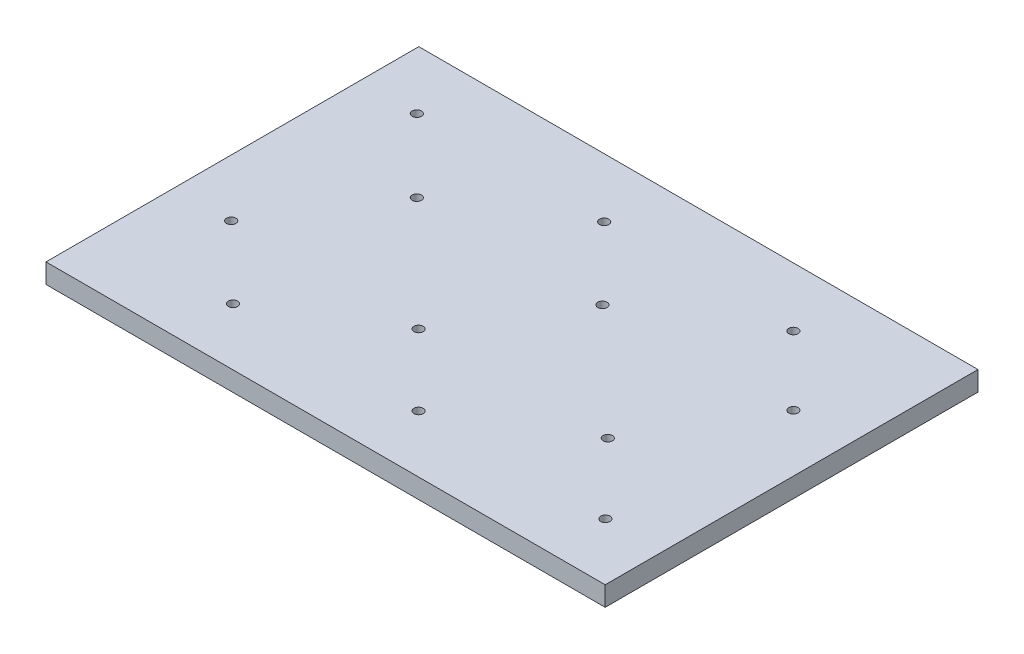
from build123d import *

# Parameters (mm, degrees)
SKETCH1_W                       = 70
SKETCH1_H                       = 50
BOSS_EXTRUDE1_DEPTH             = 6.35
SKETCH2_W                       = 60
SKETCH2_H                       = 40
CUT_EXTRUDE1_DEPTH              = 3.175
SKETCH3_W                       = 10
SKETCH3_H                       = 10
BOSS_EXTRUDE2_DEPTH             = 0.55
LPATTERN1_COUNT                 = 3
LPATTERN1_PITCH                 = 20
LPATTERN1_COUNT_DIR2            = 2
LPATTERN1_PITCH_DIR2            = 20
DIVIDERS_DEPTH                  = 2
FILLET4_R                       = 3.175
FILLET6_R                       = 3.175
FILLET7_R                       = 6.35
SKETCH11_W                      = 61.55259076
SKETCH11_H                      = 41.010160592
BOSS_EXTRUDE3_DEPTH             = 2.1
SKETCH13_W                      = 0.5
SKETCH13_H                      = 2.1
F_1_0MM_DOWEL_HOLE1_AT_2_COUNT  = 2
F_1_0MM_DOWEL_HOLE1_AT_2_PITCH  = 11.047071486
F_1_0MM_DOWEL_HOLE1_AT_3_COUNT  = 2
F_1_0MM_DOWEL_HOLE1_AT_3_PITCH  = 19.912818023
F_1_0MM_DOWEL_HOLE1_AT_4_COUNT  = 2
F_1_0MM_DOWEL_HOLE1_AT_4_PITCH  = 28.618883578
F_1_0MM_DOWEL_HOLE1_AT_5_COUNT  = 2
F_1_0MM_DOWEL_HOLE1_AT_5_PITCH  = 28.29712794
F_1_0MM_DOWEL_HOLE1_AT_6_COUNT  = 2
F_1_0MM_DOWEL_HOLE1_AT_6_PITCH  = 39.07246023
F_1_0MM_DOWEL_HOLE1_AT_7_COUNT  = 2
F_1_0MM_DOWEL_HOLE1_AT_7_PITCH  = 28.803722668
F_1_0MM_DOWEL_HOLE1_AT_8_COUNT  = 2
F_1_0MM_DOWEL_HOLE1_AT_8_PITCH  = 20.104903085
F_1_0MM_DOWEL_HOLE1_AT_9_COUNT  = 2
F_1_0MM_DOWEL_HOLE1_AT_9_PITCH  = 40.40189123
F_1_0MM_DOWEL_HOLE1_AT_10_COUNT = 2
F_1_0MM_DOWEL_HOLE1_AT_10_PITCH = 48.329363179
F_1_0MM_DOWEL_HOLE1_AT_11_COUNT = 2
F_1_0MM_DOWEL_HOLE1_AT_11_PITCH = 45.042570271
F_1_0MM_DOWEL_HOLE1_AT_12_COUNT = 2
F_1_0MM_DOWEL_HOLE1_AT_12_PITCH = 55.131944827


with BuildPart() as part:
    # Sketch1 → Boss-Extrude1 (new body)
    with BuildSketch(Plane(origin=(0, 0, 0), x_dir=(1, 0, 0), z_dir=(0, 1, 0))):
        Rectangle(SKETCH1_W, SKETCH1_H)
    extrude(amount=BOSS_EXTRUDE1_DEPTH)

    # Sketch2 → Cut-Extrude1 (cut)
    with BuildSketch(Plane(origin=(0, 6.35, 0), x_dir=(1, 0, 0), z_dir=(0, 1, 0))):
        Rectangle(SKETCH2_W, SKETCH2_H)
    extrude(amount=-CUT_EXTRUDE1_DEPTH, mode=Mode.SUBTRACT)

    # Sketch3 → Boss-Extrude2 (add)
    with BuildSketch(Plane(origin=(0, 3.175, 0), x_dir=(1, 0, 0), z_dir=(0, 1, 0))):
        with Locations((-20, 10)):
            Rectangle(SKETCH3_W, SKETCH3_H)
    boss_extrude2 = extrude(amount=BOSS_EXTRUDE2_DEPTH)

    # LPattern1: Boss-Extrude2 3 × 2
    with Locations(*[(i * LPATTERN1_PITCH, 0, j * LPATTERN1_PITCH_DIR2) for i in range(LPATTERN1_COUNT) for j in range(LPATTERN1_COUNT_DIR2) if (i, j) != (0, 0)]):
        add(boss_extrude2)

    # Fillet4
    fillet4_edges = [part.edges().sort_by_distance(p)[0] for p in [
        (35, 3.175, 25),
        (-35, 3.175, 25),
        (-35, 3.175, -25),
        (35, 3.175, -25),
    ]]
    fillet(fillet4_edges, radius=FILLET4_R)

    # Fillet6
    fillet6_edges = [part.edges().sort_by_distance(p)[0] for p in [
        (-15, 3.45, -15),
        (-25, 3.45, -5),
        (5, 3.45, -15),
        (-5, 3.45, -5),
        (25, 3.45, -15),
        (15, 3.45, -5),
    ]]
    fillet(fillet6_edges, radius=FILLET6_R)

    # Fillet7
    fillet7_edges = [part.edges().sort_by_distance(p)[0] for p in [
        (-15, 3.45, 5),
        (-25, 3.45, 15),
        (5, 3.45, 5),
        (-5, 3.45, 15),
        (25, 3.45, 5),
        (15, 3.45, 15),
    ]]
    fillet(fillet7_edges, radius=FILLET7_R)


with BuildPart() as body_2:
    # Sketch10 → Dividers (new body)
    with BuildSketch(Plane(origin=(0, 3.175, 0), x_dir=(1, 0, 0), z_dir=(0, 1, 0))):
        Polygon((-10.25, -0.25), (-10.25, -20), (-9.75, -20), (-9.75, -0.25), (9.818560524, -0.25), (9.681439476, -20), (10.181439476, -20), (10.318560524, -0.25), (30, -0.25), (30, 0.25), (10.318560524, 0.25), (10.318560524, 20), (9.818560524, 20), (9.818560524, 0.25), (-9.75, 0.25), (-9.75, 20), (-10.25, 20), (-10.25, 0.25), (-30, 0.25), (-30, -0.25), align=None)
    extrude(amount=DIVIDERS_DEPTH)


with BuildPart() as body_3:
    # Sketch11 → Boss-Extrude3 (new body)
    with BuildSketch(Plane(origin=(0, 3.175, 0), x_dir=(1, 0, 0), z_dir=(0, 1, 0))):
        Rectangle(SKETCH11_W, SKETCH11_H)
    extrude(amount=BOSS_EXTRUDE3_DEPTH)

    # Combine1: cut part
    add(part.part, mode=Mode.SUBTRACT)

    # Sketch13 → Ø1.0mm Dowel Hole1 (revolve, cut)
    with BuildSketch(Plane(origin=(-23.882575957, 5.275, -13.67005353), x_dir=(0, 0, 1), z_dir=(1, 0, 0))):
        with Locations((0.25, 1.05)):
            Rectangle(SKETCH13_W, SKETCH13_H)
    f_1_0mm_dowel_hole1 = revolve(axis=Axis((-23.882575957, 11.625, -13.67005353), (0, -1, 0)), mode=Mode.SUBTRACT)

    # Ø1.0mm Dowel Hole1 at 2: Ø1.0mm Dowel Hole1 ×2
    with Locations(*[Vector(0.707106781, 0, 0.707106781) * (i * F_1_0MM_DOWEL_HOLE1_AT_2_PITCH) for i in range(1, F_1_0MM_DOWEL_HOLE1_AT_2_COUNT)]):
        add(f_1_0mm_dowel_hole1, mode=Mode.SUBTRACT)

    # Ø1.0mm Dowel Hole1 at 3: Ø1.0mm Dowel Hole1 ×2
    with Locations(*[(0, 0, i * F_1_0MM_DOWEL_HOLE1_AT_3_PITCH) for i in range(1, F_1_0MM_DOWEL_HOLE1_AT_3_COUNT)]):
        add(f_1_0mm_dowel_hole1, mode=Mode.SUBTRACT)

    # Ø1.0mm Dowel Hole1 at 4: Ø1.0mm Dowel Hole1 ×2
    with Locations(*[Vector(0.272947725, 0, 0.962028866) * (i * F_1_0MM_DOWEL_HOLE1_AT_4_PITCH) for i in range(1, F_1_0MM_DOWEL_HOLE1_AT_4_COUNT)]):
        add(f_1_0mm_dowel_hole1, mode=Mode.SUBTRACT)

    # Ø1.0mm Dowel Hole1 at 5: Ø1.0mm Dowel Hole1 ×2
    with Locations(*[Vector(0.710492709, 0, 0.703704562) * (i * F_1_0MM_DOWEL_HOLE1_AT_5_PITCH) for i in range(1, F_1_0MM_DOWEL_HOLE1_AT_5_COUNT)]):
        add(f_1_0mm_dowel_hole1, mode=Mode.SUBTRACT)

    # Ø1.0mm Dowel Hole1 at 6: Ø1.0mm Dowel Hole1 ×2
    with Locations(*[Vector(0.709560571, 0, 0.704644447) * (i * F_1_0MM_DOWEL_HOLE1_AT_6_PITCH) for i in range(1, F_1_0MM_DOWEL_HOLE1_AT_6_COUNT)]):
        add(f_1_0mm_dowel_hole1, mode=Mode.SUBTRACT)

    # Ø1.0mm Dowel Hole1 at 7: Ø1.0mm Dowel Hole1 ×2
    with Locations(*[Vector(0.962524098, 0, 0.271196166) * (i * F_1_0MM_DOWEL_HOLE1_AT_7_PITCH) for i in range(1, F_1_0MM_DOWEL_HOLE1_AT_7_COUNT)]):
        add(f_1_0mm_dowel_hole1, mode=Mode.SUBTRACT)

    # Ø1.0mm Dowel Hole1 at 8: Ø1.0mm Dowel Hole1 ×2
    with Locations(*[(i * F_1_0MM_DOWEL_HOLE1_AT_8_PITCH, 0, 0) for i in range(1, F_1_0MM_DOWEL_HOLE1_AT_8_COUNT)]):
        add(f_1_0mm_dowel_hole1, mode=Mode.SUBTRACT)

    # Ø1.0mm Dowel Hole1 at 9: Ø1.0mm Dowel Hole1 ×2
    with Locations(*[(i * F_1_0MM_DOWEL_HOLE1_AT_9_PITCH, 0, 0) for i in range(1, F_1_0MM_DOWEL_HOLE1_AT_9_COUNT)]):
        add(f_1_0mm_dowel_hole1, mode=Mode.SUBTRACT)

    # Ø1.0mm Dowel Hole1 at 10: Ø1.0mm Dowel Hole1 ×2
    with Locations(*[Vector(0.988325705, 0, 0.152355839) * (i * F_1_0MM_DOWEL_HOLE1_AT_10_PITCH) for i in range(1, F_1_0MM_DOWEL_HOLE1_AT_10_COUNT)]):
        add(f_1_0mm_dowel_hole1, mode=Mode.SUBTRACT)

    # Ø1.0mm Dowel Hole1 at 11: Ø1.0mm Dowel Hole1 ×2
    with Locations(*[Vector(0.896971265, 0, 0.442088848) * (i * F_1_0MM_DOWEL_HOLE1_AT_11_PITCH) for i in range(1, F_1_0MM_DOWEL_HOLE1_AT_11_COUNT)]):
        add(f_1_0mm_dowel_hole1, mode=Mode.SUBTRACT)

    # Ø1.0mm Dowel Hole1 at 12: Ø1.0mm Dowel Hole1 ×2
    with Locations(*[Vector(0.866378867, 0, 0.499387283) * (i * F_1_0MM_DOWEL_HOLE1_AT_12_PITCH) for i in range(1, F_1_0MM_DOWEL_HOLE1_AT_12_COUNT)]):
        add(f_1_0mm_dowel_hole1, mode=Mode.SUBTRACT)


solid = Compound([body_2.part, body_3.part])
